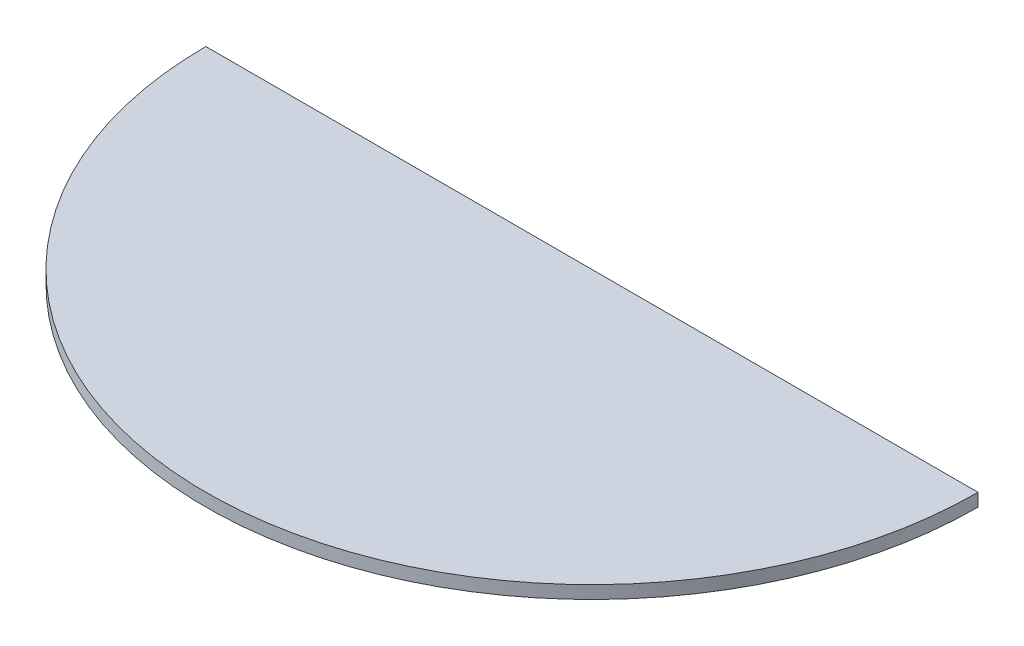
from build123d import *

# Parameters (mm, degrees)
EXTRUSION1_DEPTH = 10


with BuildPart() as part:
    # Esquisse1 → Extrusion1 (new body)
    with BuildSketch(Plane(origin=(0, 0, 0), x_dir=(1, 0, 0), z_dir=(0, 1, 0))):
        with BuildLine():
            Line((0, 0), (600, 0))
            ThreePointArc((600, 0), (300, -300), (0, 0))
        make_face()
    extrude(amount=EXTRUSION1_DEPTH)


solid = part.part
